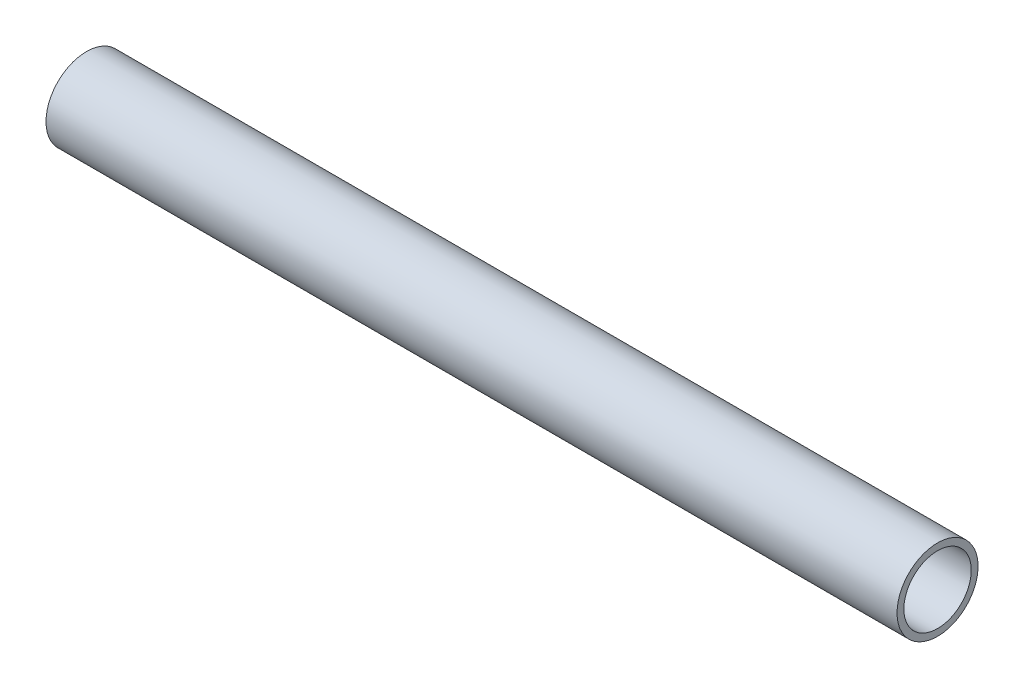
from build123d import *

# Parameters (mm, degrees)
SKETCH11_R              = 6.35
SKETCH11_R_2            = 5.2832
PIPE_0_5_SCH_40_1_DEPTH = 133.36509537


with BuildPart() as part:
    # Sketch11 → Pipe 0.5 SCH 40(1) (new body)
    with BuildSketch(Plane(origin=(158.567849637, 670.528863506, 0), x_dir=(0, -1, 0), z_dir=(-1, 0, 0))):
        Circle(SKETCH11_R)
        Circle(SKETCH11_R_2, mode=Mode.SUBTRACT)
    extrude(amount=PIPE_0_5_SCH_40_1_DEPTH)


solid = part.part
